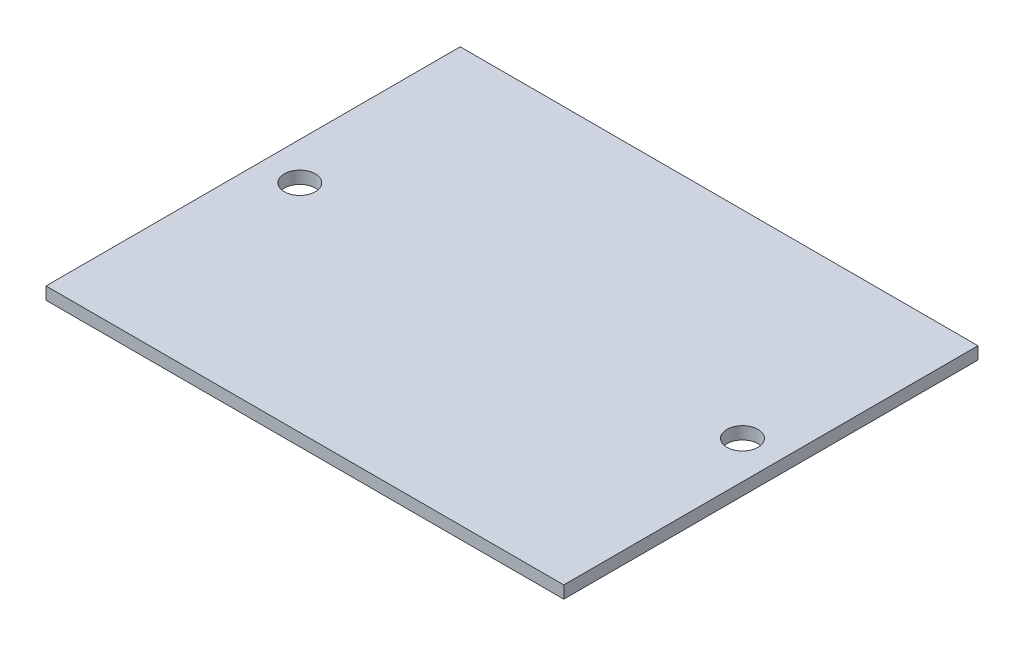
from build123d import *

# Parameters (mm, degrees)
SKETCH1_W           = 250
SKETCH1_H           = 200
SKETCH1_R           = 7.5
BOSS_EXTRUDE1_DEPTH = 5.9944


with BuildPart() as part:
    # Sketch1 → Boss-Extrude1 (new body)
    with BuildSketch(Plane(origin=(0, 0, 0), x_dir=(1, 0, 0), z_dir=(0, 1, 0))):
        with Locations((125, 100)):
            Rectangle(SKETCH1_W, SKETCH1_H)
        with Locations((18.125, 104.409742407)):
            Circle(SKETCH1_R, mode=Mode.SUBTRACT)
        with Locations((231.875, 104.409742407)):
            Circle(SKETCH1_R, mode=Mode.SUBTRACT)
    extrude(amount=BOSS_EXTRUDE1_DEPTH)


solid = part.part
